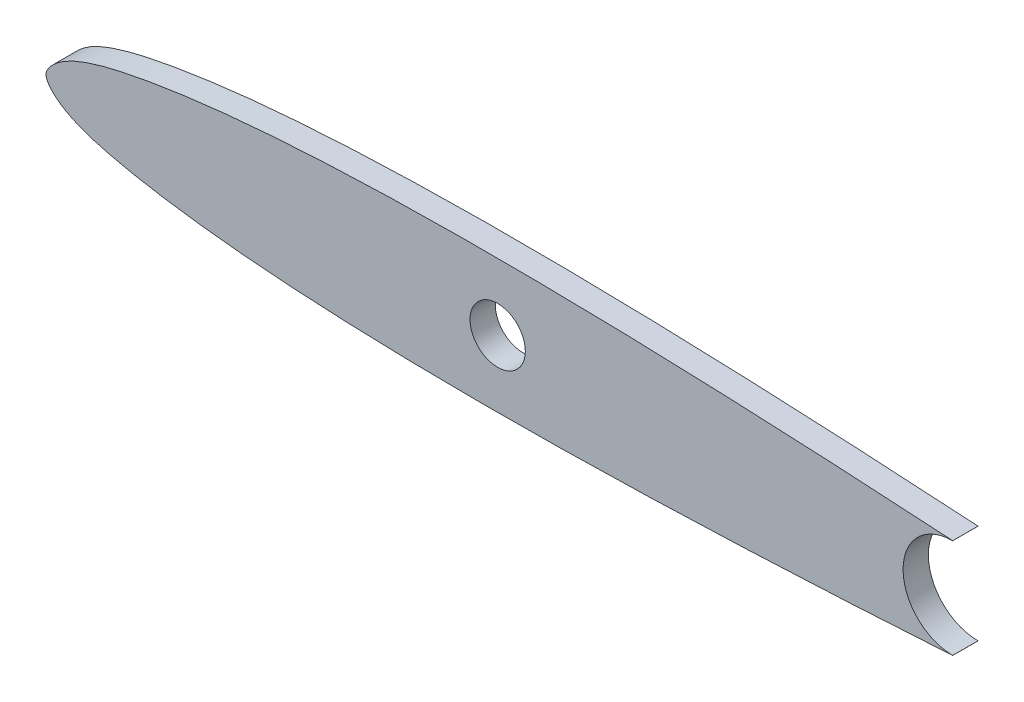
from build123d import *

# Parameters (mm, degrees)
BOSS_EXTRUDE1_DEPTH = 2.286
SKETCH6_R           = 2.499995
CUT_EXTRUDE1_DEPTH  = 3.2860001


with BuildPart() as part:
    # Sketch5 → Boss-Extrude1 (new body)
    with BuildSketch(Plane.XY):
        with BuildLine():
            add(Edge.make_bspline(
                [(133.858, 0), (133.858, 0.025572352), (132.635239995, 0.127315724), (131.381173106, 0.339626329), (128.334953604, 0.665115734), (124.592239149, 1.069140472), (119.715507644, 1.543260076), (113.989956531, 2.066482106), (107.44063652, 2.628702788), (100.204596194, 3.213470356), (92.397202136, 3.797427293), (84.154588087, 4.363270576), (75.617194084, 4.884962922), (66.93119981, 5.340411531), (58.244913897, 5.702542449), (51.072617782, 5.911739437), (45.446359676, 6.007843065), (41.353270177, 6.041949799), (37.369416299, 6.037185506), (33.511837221, 5.985902621), (29.797352234, 5.895884123), (26.2421745, 5.759936699), (22.861245753, 5.583010509), (19.66859643, 5.360981244), (16.677764128, 5.097605832), (13.902522636, 4.790578253), (11.354439687, 4.445751695), (9.043478402, 4.072015524), (6.979263272, 3.671043695), (5.168499983, 3.244225805), (3.619763578, 2.777187902), (2.336415632, 2.261279527), (1.330198654, 1.692045623), (0.606605893, 1.097639804), (0.154717172, 0.552843268), (-0.063310242, 3e-08), (0.154717172, -0.552843207), (0.606605893, -1.097639744), (1.330198653, -1.692045564), (2.336415631, -2.261279467), (3.619763576, -2.777187843), (5.168499981, -3.244225747), (6.97926327, -3.671043638), (9.0434784, -4.072015468), (11.354439685, -4.445751639), (13.902522634, -4.790578199), (16.677764125, -5.09760578), (19.668596427, -5.360981193), (22.861245751, -5.583010459), (26.242174497, -5.75993665), (29.797352231, -5.895884076), (33.511837218, -5.985902576), (37.369416296, -6.037185463), (41.353270174, -6.041949758), (45.446359674, -6.007843025), (51.07261778, -5.9117394), (58.244913895, -5.702542415), (66.931199807, -5.340411501), (75.617194082, -4.884962895), (84.154588085, -4.363270553), (92.397202135, -3.797427274), (100.204596193, -3.213470341), (107.440636519, -2.628702776), (113.98995653, -2.066482097), (119.715507643, -1.54326007), (124.592239149, -1.069140468), (128.334953604, -0.665115731), (131.381173106, -0.339626328), (132.635239995, -0.127315723), (133.858, -0.025572352), (133.858, 0)],
                knots=[0, 0, 0, 0, 0.002133427, 0.008488156, 0.018944487, 0.033319114, 0.051356294, 0.072756093, 0.097140817, 0.124097489, 0.153162557, 0.183833918, 0.215589374, 0.247878195, 0.280150868, 0.311860397, 0.327332943, 0.342462846, 0.357187102, 0.371448118, 0.385183441, 0.398331273, 0.410844637, 0.422672607, 0.433769314, 0.444090175, 0.453589412, 0.46224044, 0.470010037, 0.476870985, 0.482833353, 0.487908551, 0.492155164, 0.495592273, 0.498196359, 0.5, 0.501803641, 0.504407727, 0.507844836, 0.512091449, 0.517166647, 0.523129015, 0.529989963, 0.53775956, 0.546410588, 0.555909825, 0.566230686, 0.577327393, 0.589155363, 0.601668727, 0.614816559, 0.628551882, 0.642812898, 0.657537154, 0.672667057, 0.688139603, 0.719849132, 0.752121805, 0.784410626, 0.816166082, 0.846837443, 0.875902511, 0.902859183, 0.927243907, 0.948643706, 0.966680886, 0.981055513, 0.991511844, 0.997866573, 1, 1, 1, 1], degree=3))
        make_face()
    extrude(amount=BOSS_EXTRUDE1_DEPTH)

    # Sketch6 → Cut-Extrude1 (cut, through all)
    with BuildSketch(Plane.XY.offset(2.286)):
        with Locations((40.82669, 0)):
            Circle(SKETCH6_R)
        with BuildLine():
            Line((81.960834953, -5.493044859), (81.960834953, -4.487637978))
            ThreePointArc((81.960834953, -4.487637978), (77.473196974, 0), (81.960834953, 4.487637978))
            Line((81.960834953, 4.487637978), (81.960834953, 6.547183649))
            Line((81.960834953, 6.547183649), (133.858, 6.547183649))
            Line((133.858, 6.547183649), (133.858, -10.908900774))
            Line((133.858, -10.908900774), (81.960834953, -5.493044859))
        make_face()
    extrude(amount=-CUT_EXTRUDE1_DEPTH, mode=Mode.SUBTRACT)


solid = part.part
